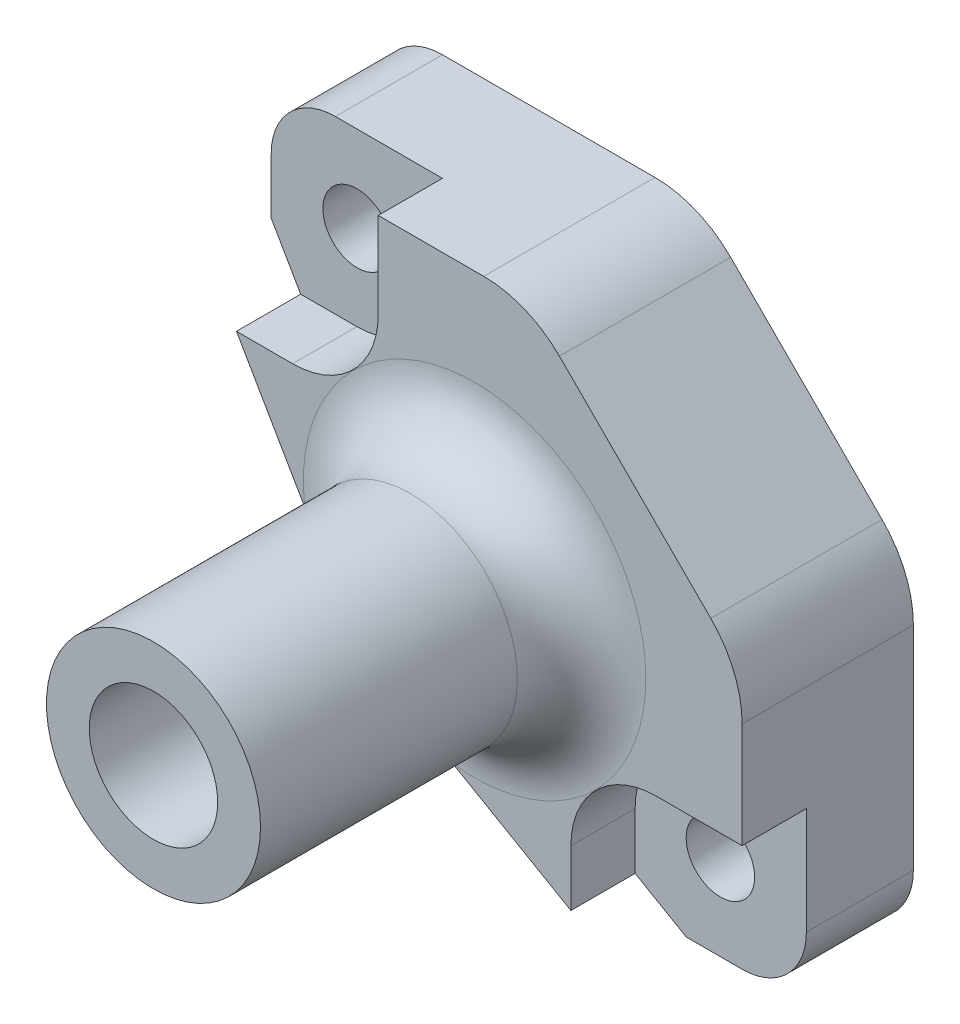
from build123d import *

# Parameters (mm, degrees)
SCHIZZO1_W                            = 25
SCHIZZO1_H                            = 25
ESTRUSIONE_ESTRUSIONE1_DEPTH          = 8
SCHIZZO8_R                            = 5
ESTRUSIONE_ESTRUSIONE3_DEPTH          = 15
RACCORDO1_R                           = 3
TAGLIO_ESTRUSIONE2_REACH              = 25
SCHIZZO9_R                            = 1.6
SCHIZZO10_R                           = 3
TAGLIO_ESTRUSIONE3_DEPTH              = 4
SCHIZZO11_R                           = 3
TAGLIO_ESTRUSIONE4_DEPTH              = 16
TAGLIO_ESTRUSIONE6_REACH              = 25
SCHIZZO13_R                           = 1.6
TAGLIO_ESTRUSIONE8_START              = -3
TAGLIO_ESTRUSIONE8_DEPTH              = 19
RIPETIZIONECIRCOLARE1_COUNT           = 2
RIPETIZIONECIRCOLARE1_ANGLE           = 180
TAGLIO_ESTRUSIONE9_REACH              = 10
RACCORDO2_R                           = 5
RACCORDO3_R                           = 3
TAGLIO_ESTRUSIONE10_REACH             = 10
TAGLIO_ESTRUSIONE10_DIRECTION_2_REACH = 17


with BuildPart() as part:
    # Schizzo1 → Estrusione-Estrusione1 (new body)
    with BuildSketch(Plane.XY):
        Rectangle(SCHIZZO1_W, SCHIZZO1_H)
    extrude(amount=ESTRUSIONE_ESTRUSIONE1_DEPTH)

    # Schizzo8 → Estrusione-Estrusione3 (add)
    with BuildSketch(Plane.XY.offset(8)):
        Circle(SCHIZZO8_R)
    extrude(amount=ESTRUSIONE_ESTRUSIONE3_DEPTH)

    # Raccordo1
    raccordo1_edges = [part.edges().sort_by_distance(p)[0] for p in [
        (-5, 0, 8),
    ]]
    fillet(raccordo1_edges, radius=RACCORDO1_R)

    # Schizzo9 → Taglio-Estrusione2 (cut, up to next)
    with BuildSketch(Plane(origin=(0, 0, 0), x_dir=(-1, 0, 0), z_dir=(0, 0, -1)), mode=Mode.PRIVATE) as taglio_estrusione2_sk1:
        Circle(SCHIZZO9_R)
    taglio_estrusione2_tool1 = extrude(taglio_estrusione2_sk1.sketch, amount=-TAGLIO_ESTRUSIONE2_REACH, mode=Mode.PRIVATE) & part.part
    add(taglio_estrusione2_tool1.solids().sort_by_distance((0, 0, 0))[0], mode=Mode.SUBTRACT)

    # Schizzo10 → Taglio-Estrusione3 (cut)
    with BuildSketch(Plane(origin=(0, 0, 0), x_dir=(-1, 0, 0), z_dir=(0, 0, -1))):
        Circle(SCHIZZO10_R)
    extrude(amount=-TAGLIO_ESTRUSIONE3_DEPTH, mode=Mode.SUBTRACT)

    # Schizzo11 → Taglio-Estrusione4 (cut)
    with BuildSketch(Plane.XY.offset(23)):
        Circle(SCHIZZO11_R)
    extrude(amount=-TAGLIO_ESTRUSIONE4_DEPTH, mode=Mode.SUBTRACT)

    # Schizzo13 → Taglio-Estrusione6 (cut, up to next)
    with BuildSketch(Plane(origin=(0, 0, 0), x_dir=(-1, 0, 0), z_dir=(0, 0, -1)), mode=Mode.PRIVATE) as taglio_estrusione6_sk1:
        with Locations((-8.485281374, -8.485281374)):
            Circle(SCHIZZO13_R)
    taglio_estrusione6_tool1 = extrude(taglio_estrusione6_sk1.sketch, amount=-TAGLIO_ESTRUSIONE6_REACH, mode=Mode.PRIVATE) & part.part
    add(taglio_estrusione6_tool1.solids().sort_by_distance((8.485281, -8.485281, 0))[0], mode=Mode.SUBTRACT)
    # Schizzo13 → Taglio-Estrusione6 (cut, up to next)
    with BuildSketch(Plane(origin=(0, 0, 0), x_dir=(-1, 0, 0), z_dir=(0, 0, -1)), mode=Mode.PRIVATE) as taglio_estrusione6_sk2:
        with Locations((8.485281374, 8.485281374)):
            Circle(SCHIZZO13_R)
    taglio_estrusione6_tool2 = extrude(taglio_estrusione6_sk2.sketch, amount=-TAGLIO_ESTRUSIONE6_REACH, mode=Mode.PRIVATE) & part.part
    add(taglio_estrusione6_tool2.solids().sort_by_distance((-8.485281, 8.485281, 0))[0], mode=Mode.SUBTRACT)

    # Schizzo17 → Taglio-Estrusione8 (cut)
    with BuildSketch(Plane.XY.offset(8).offset(TAGLIO_ESTRUSIONE8_START)):
        with BuildLine():
            Line((4.5, -12.5), (4.5, -8.5))
            ThreePointArc((4.5, -8.5), (5.671572875, -5.671572875), (8.5, -4.5))
            Line((8.5, -4.5), (12.5, -4.5))
            Line((12.5, -4.5), (12.5, -12.5))
            Line((12.5, -12.5), (4.5, -12.5))
        make_face()
    taglio_estrusione8 = extrude(amount=TAGLIO_ESTRUSIONE8_DEPTH, mode=Mode.SUBTRACT)

    # RipetizioneCircolare1: Taglio-Estrusione8 ×2 about axis
    ripetizionecircolare1_axis = Axis((0, 0, 0), (0, 0, 1))
    for i in range(1, RIPETIZIONECIRCOLARE1_COUNT):
        add(taglio_estrusione8.rotate(ripetizionecircolare1_axis, i * RIPETIZIONECIRCOLARE1_ANGLE / (RIPETIZIONECIRCOLARE1_COUNT - 1)), mode=Mode.SUBTRACT)

    # Schizzo18 → Taglio-Estrusione9 (cut, up to next)
    with BuildSketch(Plane.XY.offset(8), mode=Mode.PRIVATE) as taglio_estrusione9_sk1:
        Polygon((2.5, 12.5), (12.5, 2.5), (12.5, 12.5), align=None)
    taglio_estrusione9_tool1 = extrude(taglio_estrusione9_sk1.sketch, amount=-TAGLIO_ESTRUSIONE9_REACH, mode=Mode.PRIVATE) & part.part
    add(taglio_estrusione9_tool1.solids().sort_by_distance((9.166667, 9.166667, 8))[0], mode=Mode.SUBTRACT)

    # Raccordo2
    raccordo2_edges = [part.edges().sort_by_distance(p)[0] for p in [
        (2.5, 12.5, 4),
        (12.5, 2.5, 4),
    ]]
    fillet(raccordo2_edges, radius=RACCORDO2_R)

    # Raccordo3
    raccordo3_edges = [part.edges().sort_by_distance(p)[0] for p in [
        (12.5, -12.5, 2.5),
        (-12.5, 12.5, 2.5),
    ]]
    fillet(raccordo3_edges, radius=RACCORDO3_R)

    # Schizzo19 → Taglio-Estrusione10 (cut, up to next)
    with BuildSketch(Plane.XY.offset(8), mode=Mode.PRIVATE) as taglio_estrusione10_sk1:
        with BuildLine():
            Line((4.5, -12.5), (6.885281374, -12.5))
            Line((6.885281374, -12.5), (-1.022619302, -7.934371416))
            ThreePointArc((-1.022619302, -7.934371416), (-4.933470073, -4.933470073), (-7.934371416, -1.022619302))
            Line((-7.934371416, -1.022619302), (-12.5, 6.885281374))
            Line((-12.5, 6.885281374), (-12.5, 4.5))
            Line((-12.5, 4.5), (-12.5, -12.5))
            Line((-12.5, -12.5), (4.5, -12.5))
        make_face()
    taglio_estrusione10_tool1 = extrude(taglio_estrusione10_sk1.sketch, amount=-TAGLIO_ESTRUSIONE10_REACH, mode=Mode.PRIVATE) & part.part
    add(taglio_estrusione10_tool1.solids().sort_by_distance((-6.87454, -6.87454, 8))[0], mode=Mode.SUBTRACT)

    # Schizzo19 → Taglio-Estrusione10 direction 2 (cut, up to next)
    with BuildSketch(Plane.XY.offset(8), mode=Mode.PRIVATE) as taglio_estrusione10_direction_2_sk1:
        with BuildLine():
            Line((4.5, -12.5), (6.885281374, -12.5))
            Line((6.885281374, -12.5), (-1.022619302, -7.934371416))
            ThreePointArc((-1.022619302, -7.934371416), (-4.933470073, -4.933470073), (-7.934371416, -1.022619302))
            Line((-7.934371416, -1.022619302), (-12.5, 6.885281374))
            Line((-12.5, 6.885281374), (-12.5, 4.5))
            Line((-12.5, 4.5), (-12.5, -12.5))
            Line((-12.5, -12.5), (4.5, -12.5))
        make_face()
    taglio_estrusione10_direction_2_tool1 = extrude(taglio_estrusione10_direction_2_sk1.sketch, amount=TAGLIO_ESTRUSIONE10_DIRECTION_2_REACH, mode=Mode.PRIVATE) & part.part
    add(taglio_estrusione10_direction_2_tool1.solids().sort_by_distance((-6.87454, -6.87454, 8))[0], mode=Mode.SUBTRACT)


solid = part.part
